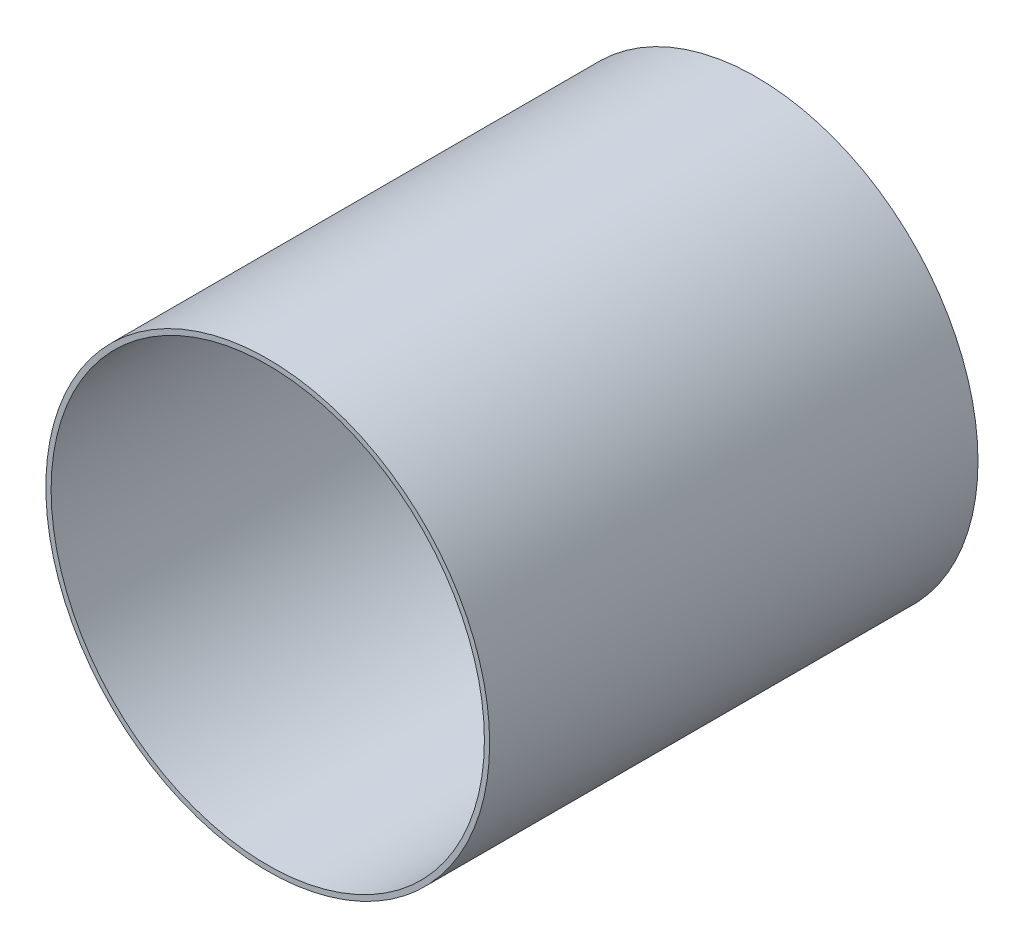
from build123d import *

# Parameters (mm, degrees)
SKETCH1_R           = 63.4746
SKETCH1_R_2         = 61.976
BOSS_EXTRUDE1_DEPTH = 69.85


with BuildPart() as part:
    # Sketch1 → Boss-Extrude1 (new body, symmetric)
    with BuildSketch(Plane.XY):
        Circle(SKETCH1_R)
        Circle(SKETCH1_R_2, mode=Mode.SUBTRACT)
    extrude(amount=BOSS_EXTRUDE1_DEPTH, both=True)


solid = part.part
